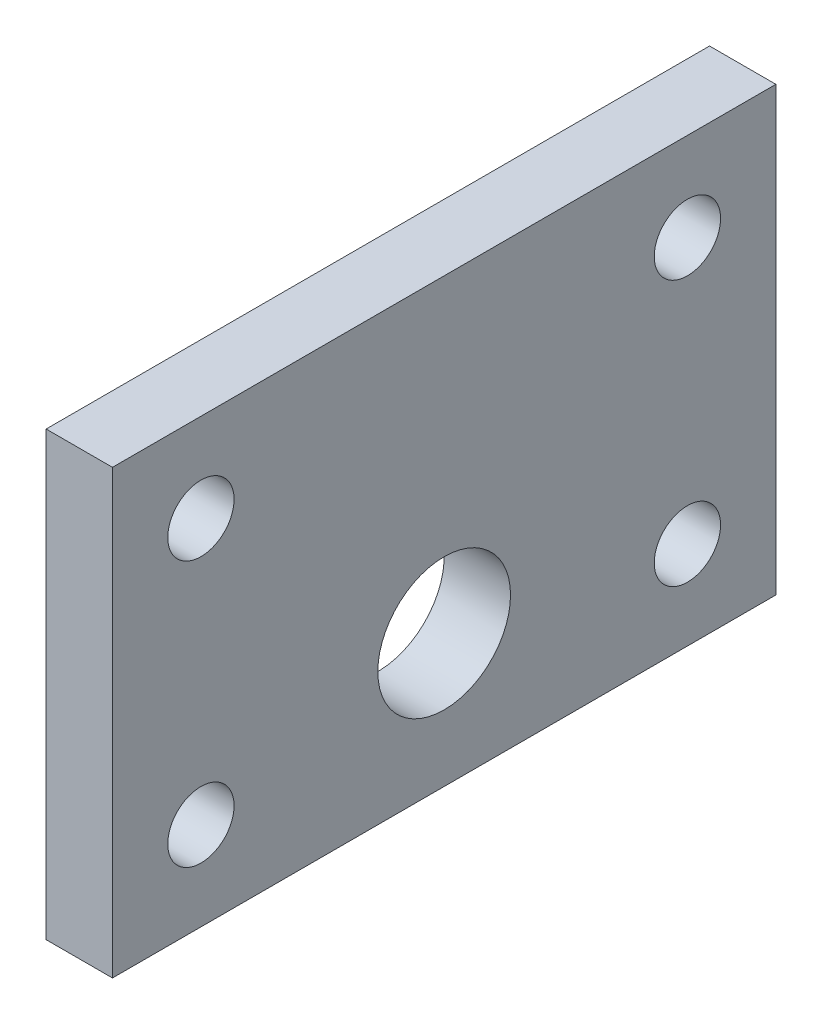
from build123d import *

# Parameters (mm, degrees)
SKETCH_1_W          = 30
SKETCH_1_H          = 20
SKETCH_1_R          = 1.5
EXTRUDE_1_DEPTH     = 3
CUT_EXTRUDE_1_REACH = 5
SKETCH_2_R          = 3


with BuildPart() as part:
    # 草图1 → 凸台-拉伸1 (new body)
    with BuildSketch(Plane(origin=(0, 0, 0), x_dir=(0, 0, -1), z_dir=(1, 0, 0))):
        Rectangle(SKETCH_1_W, SKETCH_1_H)
        with Locations((-11, 6)):
            Circle(SKETCH_1_R, mode=Mode.SUBTRACT)
        with Locations((-11, -6)):
            Circle(SKETCH_1_R, mode=Mode.SUBTRACT)
        with Locations((11, -6)):
            Circle(SKETCH_1_R, mode=Mode.SUBTRACT)
        with Locations((11, 6)):
            Circle(SKETCH_1_R, mode=Mode.SUBTRACT)
    extrude(amount=EXTRUDE_1_DEPTH)

    # 草图2 → 切除-拉伸1 (cut, up to next)
    with BuildSketch(Plane.ZY, mode=Mode.PRIVATE) as cut_extrude_1_sk1:
        with Locations((0, -4)):
            Circle(SKETCH_2_R)
    cut_extrude_1_tool1 = extrude(cut_extrude_1_sk1.sketch, amount=-CUT_EXTRUDE_1_REACH, mode=Mode.PRIVATE) & part.part
    add(cut_extrude_1_tool1.solids().sort_by_distance((0, -4, 0))[0], mode=Mode.SUBTRACT)


solid = part.part
